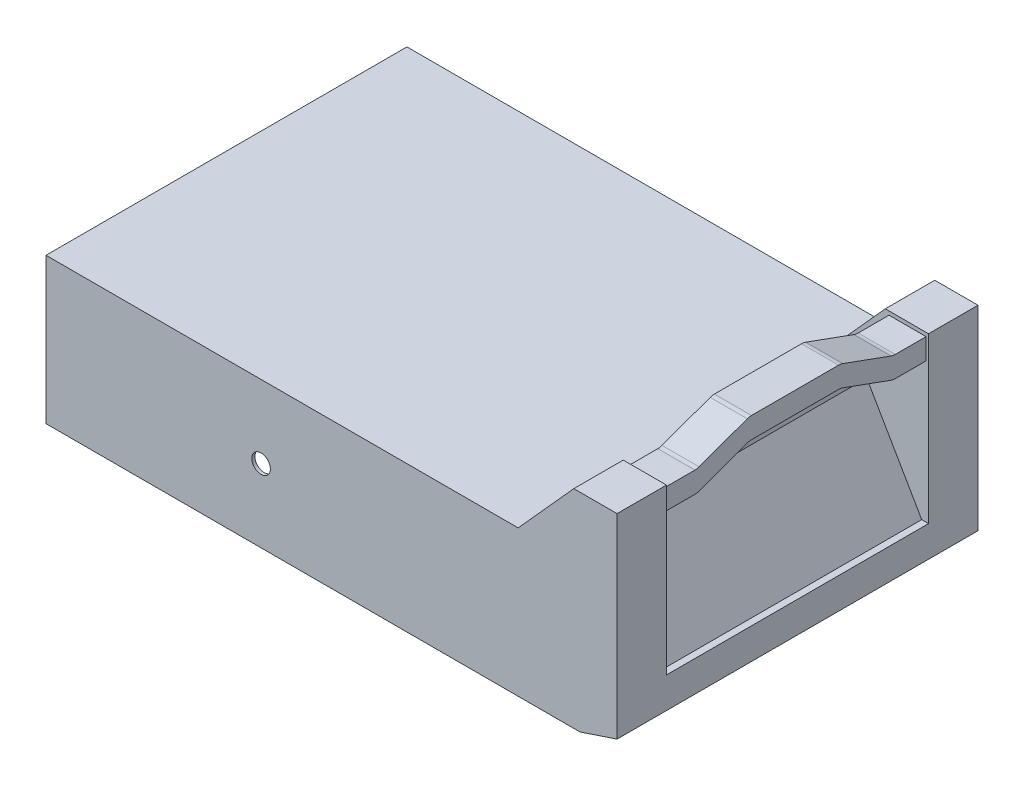
from build123d import *

# Parameters (mm, degrees)
SKETCH1_W           = 462
SKETCH1_H           = 292
BOSS_EXTRUDE1_DEPTH = 118
CHAMFER1_SIZE       = 30
CHAMFER1_SIZE2      = 10
SKETCH2_W           = 80
SKETCH2_H           = 40
BOSS_EXTRUDE2_DEPTH = 50
CUT_EXTRUDE1_DEPTH  = 293
SKETCH5_W           = 212
SKETCH5_H           = 83
CUT_EXTRUDE3_DEPTH  = 50
BOSS_EXTRUDE3_DEPTH = 30
BOSS_EXTRUDE5_REACH = 254
SHELL1_T            = -2.5
SKETCH9_R           = 7.5
CUT_EXTRUDE4_DEPTH  = 293


with BuildPart() as part:
    # Sketch1 → Boss-Extrude1 (new body)
    with BuildSketch(Plane(origin=(0, 0, 0), x_dir=(1, 0, 0), z_dir=(0, 1, 0))):
        Rectangle(SKETCH1_W, SKETCH1_H)
    extrude(amount=BOSS_EXTRUDE1_DEPTH)

    # Chamfer1
    chamfer1_edges = [part.edges().sort_by_distance(p)[0] for p in [
        (231, 0, 0),
    ]]
    chamfer1_side = [part.faces().sort_by_distance(p)[0] for p in [
        (0, 0, 0),
    ]]
    chamfer(chamfer1_edges, length=CHAMFER1_SIZE, length2=CHAMFER1_SIZE2, reference=chamfer1_side[0])

    # Sketch2 → Boss-Extrude2 (add)
    with BuildSketch(Plane(origin=(0, 118, 0), x_dir=(1, 0, 0), z_dir=(0, 1, 0))):
        with Locations((191, 126)):
            Rectangle(SKETCH2_W, SKETCH2_H)
        with Locations((191, -126)):
            Rectangle(SKETCH2_W, SKETCH2_H)
    extrude(amount=BOSS_EXTRUDE2_DEPTH)

    # Sketch3 → Cut-Extrude1 (cut, through all)
    with BuildSketch(Plane.XY.offset(146)):
        Polygon((151, 118), (196, 168), (151, 168), align=None)
    extrude(amount=-CUT_EXTRUDE1_DEPTH, mode=Mode.SUBTRACT)

    # Sketch5 → Cut-Extrude3 (cut)
    with BuildSketch(Plane(origin=(231, 0, 0), x_dir=(0, 0, -1), z_dir=(1, 0, 0))):
        with Locations((0, 76.5)):
            Rectangle(SKETCH5_W, SKETCH5_H)
    extrude(amount=-CUT_EXTRUDE3_DEPTH, mode=Mode.SUBTRACT)

    # Sketch6 → Boss-Extrude3 (add)
    with BuildSketch(Plane(origin=(199, 0, 0), x_dir=(0, 0, -1), z_dir=(1, 0, 0))):
        with BuildLine():
            Line((106, 165), (81.049437742, 165))
            ThreePointArc((81.049437742, 165), (79.312955966, 165.15192247), (77.629236309, 165.603073792))
            Line((77.629236309, 165.603073792), (38.656931626, 179.787832658))
            ThreePointArc((38.656931626, 179.787832658), (36.97321197, 180.23898398), (35.236730193, 180.39090645))
            Line((35.236730193, 180.39090645), (-35.236730193, 180.39090645))
            ThreePointArc((-35.236730193, 180.39090645), (-36.97321197, 180.23898398), (-38.656931626, 179.787832658))
            Line((-38.656931626, 179.787832658), (-77.629236309, 165.603073792))
            ThreePointArc((-77.629236309, 165.603073792), (-79.312955966, 165.15192247), (-81.049437742, 165))
            Line((-81.049437742, 165), (-106, 165))
            Line((-106, 165), (-106, 148))
            Line((-106, 148), (-81.049437742, 148))
            ThreePointArc((-81.049437742, 148), (-79.312955966, 148.15192247), (-77.629236309, 148.603073792))
            Line((-77.629236309, 148.603073792), (-38.656931626, 162.787832658))
            ThreePointArc((-38.656931626, 162.787832658), (-36.97321197, 163.23898398), (-35.236730193, 163.39090645))
            Line((-35.236730193, 163.39090645), (35.236730193, 163.39090645))
            ThreePointArc((35.236730193, 163.39090645), (36.97321197, 163.23898398), (38.656931626, 162.787832658))
            Line((38.656931626, 162.787832658), (77.629236309, 148.603073792))
            ThreePointArc((77.629236309, 148.603073792), (79.312955966, 148.15192247), (81.049437742, 148))
            Line((81.049437742, 148), (106, 148))
            Line((106, 148), (106, 165))
        make_face()
    extrude(amount=BOSS_EXTRUDE3_DEPTH)

    # Sketch8 → Boss-Extrude5 (add, up to next)
    with BuildSketch(Plane.XY.offset(-106), mode=Mode.PRIVATE) as boss_extrude5_sk1:
        Polygon((181, 112), (225.455970728, 35), (181, 35), align=None)
    boss_extrude5_tool1 = extrude(boss_extrude5_sk1.sketch, amount=BOSS_EXTRUDE5_REACH, mode=Mode.PRIVATE) - part.part
    add(boss_extrude5_tool1.solids().sort_by_distance((195.818657, 60.666667, -106))[0])

    # Shell1
    shell1_openings = [part.faces().sort_by_distance(p)[0] for p in [
        (-15, 0, 0),
    ]]
    offset(amount=SHELL1_T, openings=shell1_openings, kind=Kind.INTERSECTION)

    # Sketch9 → Cut-Extrude4 (cut, through all)
    with BuildSketch(Plane.XY.offset(146)):
        with Locations((-57, 59)):
            Circle(SKETCH9_R)
    extrude(amount=-CUT_EXTRUDE4_DEPTH, mode=Mode.SUBTRACT)


solid = part.part
